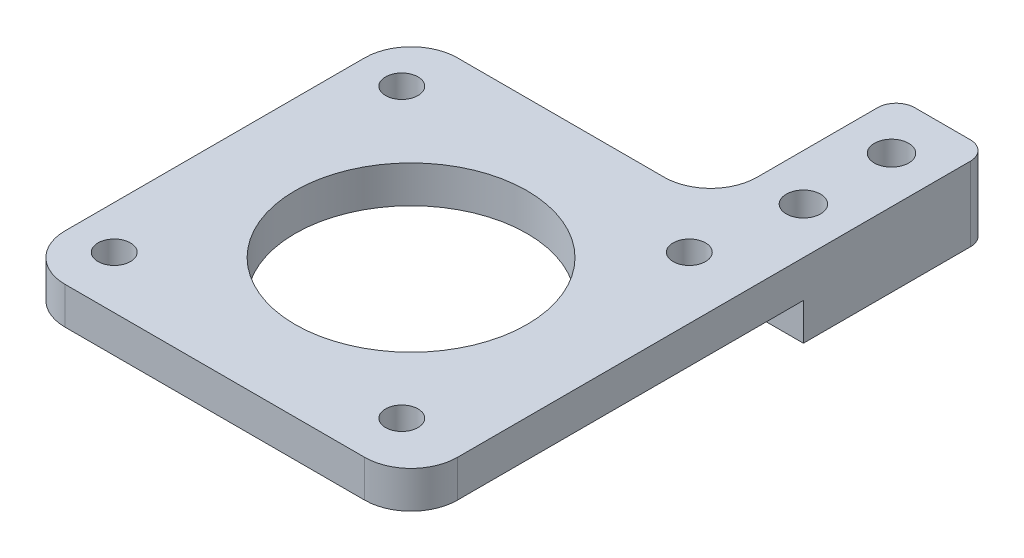
from build123d import *

# Parameters (mm, degrees)
SKETCH2_R           = 1.75
SKETCH2_R_2         = 12.5
SKETCH2_R_3         = 1.85
BOSS_EXTRUDE1_DEPTH = 4
FILLET1_R           = 5
FILLET8_R           = 5
SKETCH5_R           = 1.85
BOSS_EXTRUDE2_DEPTH = 4
FILLET10_R          = 2


with BuildPart() as part:
    # Sketch2 → Boss-Extrude1 (new body)
    with BuildSketch(Plane(origin=(0, 0, 0), x_dir=(1, 0, 0), z_dir=(0, 1, 0))):
        Polygon((-30.65, 0), (-30.65, 42.3), (1.65, 42.3), (1.65, 62.3), (11.65, 62.3), (11.65, 42.3), (11.65, 0), align=None)
        with Locations((5, 5.65)):
            Circle(SKETCH2_R, mode=Mode.SUBTRACT)
        with Locations((5, 36.65)):
            Circle(SKETCH2_R, mode=Mode.SUBTRACT)
        with Locations((-26, 5.65)):
            Circle(SKETCH2_R, mode=Mode.SUBTRACT)
        with Locations((-26, 36.65)):
            Circle(SKETCH2_R, mode=Mode.SUBTRACT)
        with Locations((-9.5, 21.15)):
            Circle(SKETCH2_R_2, mode=Mode.SUBTRACT)
        with Locations((6.65, 56.8)):
            Circle(SKETCH2_R_3, mode=Mode.SUBTRACT)
        with Locations((6.65, 47.3)):
            Circle(SKETCH2_R_3, mode=Mode.SUBTRACT)
    extrude(amount=BOSS_EXTRUDE1_DEPTH)

    # Fillet1
    fillet1_edges = [part.edges().sort_by_distance(p)[0] for p in [
        (11.65, 2, 0),
        (-30.65, 2, 0),
        (-30.65, 2, -42.3),
    ]]
    fillet(fillet1_edges, radius=FILLET1_R)

    # Fillet8
    fillet8_edges = [part.edges().sort_by_distance(p)[0] for p in [
        (1.65, 2, -42.3),
    ]]
    fillet(fillet8_edges, radius=FILLET8_R)

    # Sketch5 → Boss-Extrude2 (add)
    with BuildSketch(Plane.XZ):
        with BuildLine():
            Line((11.65, -62.3), (1.65, -62.3))
            Line((1.65, -62.3), (1.65, -47.3))
            ThreePointArc((1.65, -47.3), (0.185533906, -43.764466094), (-3.35, -42.3))
            Line((-3.35, -42.3), (11.65, -42.3))
            Line((11.65, -42.3), (11.65, -62.3))
        make_face()
        with Locations((6.65, -47.3)):
            Circle(SKETCH5_R, mode=Mode.SUBTRACT)
        with Locations((6.65, -56.8)):
            Circle(SKETCH5_R, mode=Mode.SUBTRACT)
    extrude(amount=BOSS_EXTRUDE2_DEPTH)

    # Fillet10
    fillet10_edges = [part.edges().sort_by_distance(p)[0] for p in [
        (1.65, 0, -62.3),
        (11.65, 0, -62.3),
    ]]
    fillet(fillet10_edges, radius=FILLET10_R)


solid = part.part
